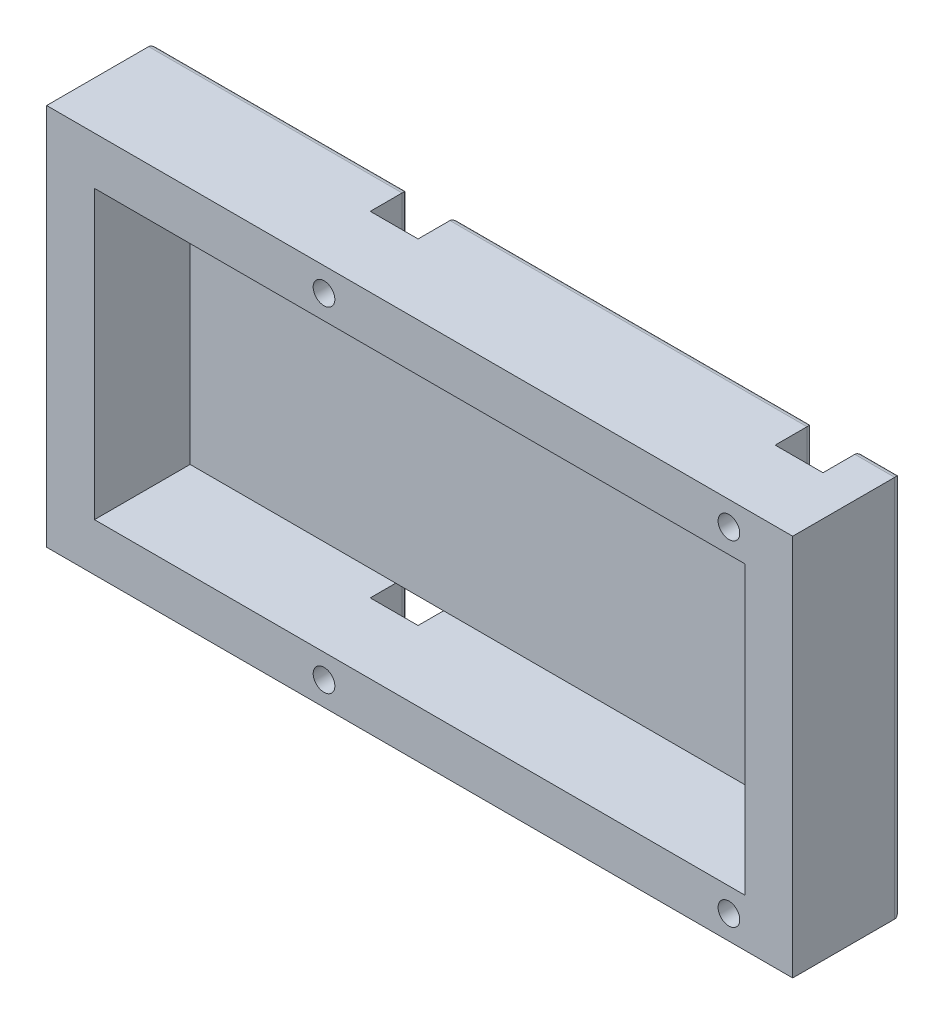
from build123d import *

# Parameters (mm, degrees)
SKETCH_1_W          = 117
SKETCH_1_H          = 60
EXTRUDE_1_DEPTH     = 17
SKETCH_2_W          = 102
SKETCH_2_H          = 45
CUT_EXTRUDE_1_DEPTH = 15
SKETCH_4_R          = 1.7
CUT_EXTRUDE_2_DEPTH = 18
SKETCH_5_W          = 7.5
SKETCH_5_H          = 7.5
CUT_EXTRUDE_3_DEPTH = 6
FILLET_2_R          = 1


with BuildPart() as part:
    # ｽｹｯﾁ1 → ﾎﾞｽ - 押し出し1 (new body)
    with BuildSketch(Plane.XY):
        Rectangle(SKETCH_1_W, SKETCH_1_H)
    extrude(amount=EXTRUDE_1_DEPTH)

    # ｽｹｯﾁ2 → ｶｯﾄ - 押し出し1 (cut)
    with BuildSketch(Plane.XY.offset(17)):
        Rectangle(SKETCH_2_W, SKETCH_2_H)
    extrude(amount=-CUT_EXTRUDE_1_DEPTH, mode=Mode.SUBTRACT)

    # ｽｹｯﾁ4 → ｶｯﾄ - 押し出し2 (cut, through all)
    with BuildSketch(Plane(origin=(0, 0, 0), x_dir=(-1, 0, 0), z_dir=(0, 0, -1))):
        with Locations((15, 26.25)):
            Circle(SKETCH_4_R)
        with Locations((15, -26.25)):
            Circle(SKETCH_4_R)
        with Locations((-48.5, -26.25)):
            Circle(SKETCH_4_R)
        with Locations((-48.5, 26.25)):
            Circle(SKETCH_4_R)
    extrude(amount=-CUT_EXTRUDE_2_DEPTH, mode=Mode.SUBTRACT)

    # ｽｹｯﾁ5 → ｶｯﾄ - 押し出し3 (cut)
    with BuildSketch(Plane(origin=(0, 0, 0), x_dir=(-1, 0, 0), z_dir=(0, 0, -1))):
        with Locations((-48.5, -26.25)):
            Rectangle(SKETCH_5_W, SKETCH_5_H)
        with Locations((-48.5, 26.25)):
            Rectangle(SKETCH_5_W, SKETCH_5_H)
        with Locations((15, 26.25)):
            Rectangle(SKETCH_5_W, SKETCH_5_H)
        with Locations((15, -26.25)):
            Rectangle(SKETCH_5_W, SKETCH_5_H)
    extrude(amount=-CUT_EXTRUDE_3_DEPTH, mode=Mode.SUBTRACT)

    # ﾌｨﾚｯﾄ2
    fillet_2_edges = [part.edges().sort_by_distance(p)[0] for p in [
        (55.375, 30, 0),
        (58.5, 0, 0),
        (16.75, 30, 0),
        (-38.625, 30, 0),
        (16.75, -30, 0),
        (55.375, -30, 0),
        (-38.625, -30, 0),
        (-58.5, 0, 0),
        (-18.75, -26.25, 0),
        (-15, -22.5, 0),
        (-11.25, -26.25, 0),
        (-18.75, 26.25, 0),
        (-11.25, 26.25, 0),
        (-15, 22.5, 0),
        (44.75, 26.25, 0),
        (52.25, 26.25, 0),
        (48.5, 22.5, 0),
        (44.75, -26.25, 0),
        (48.5, -22.5, 0),
        (52.25, -26.25, 0),
    ]]
    fillet(fillet_2_edges, radius=FILLET_2_R)


solid = part.part
